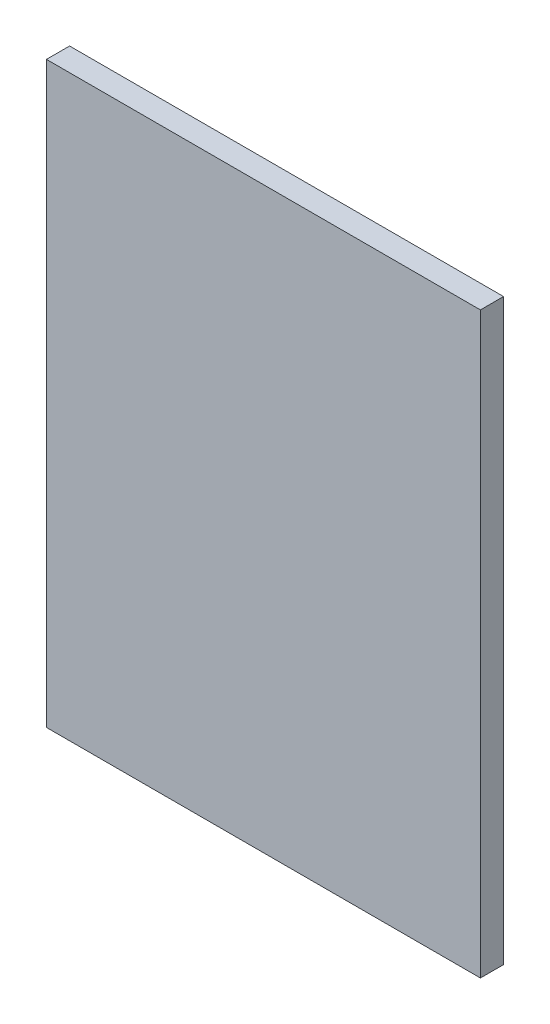
from build123d import *

# Parameters (mm, degrees)
SKETCH1_W           = 150
SKETCH1_H           = 200
BOSS_EXTRUDE1_DEPTH = 8


with BuildPart() as part:
    # Sketch1 → Boss-Extrude1 (new body)
    with BuildSketch(Plane.XY):
        with Locations((-45.412844037, 68.119266055)):
            Rectangle(SKETCH1_W, SKETCH1_H)
    extrude(amount=BOSS_EXTRUDE1_DEPTH)


solid = part.part
